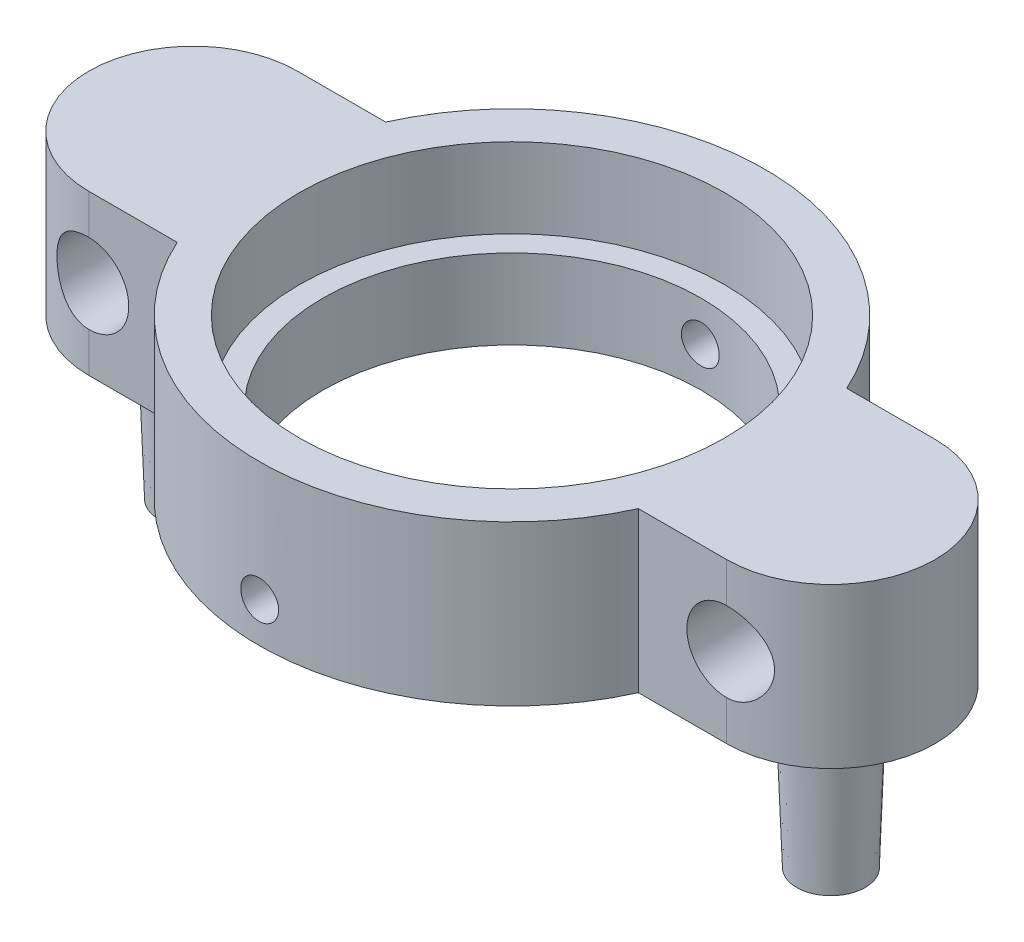
from build123d import *

# Parameters (mm, degrees)
SKETCH1_R                          = 11.303
BOSS_EXTRUDE1_DEPTH                = 9.525
F_4_40_TAPPED_HOLE1_D              = 2.2606
SKETCH10_R                         = 2.38125
BOSS_EXTRUDE2_DEPTH                = 9.525
BOSS_EXTRUDE2_TAPER                = 2
F_3_16_0_1875_DIAMETER_HOLE1_D     = 4.7625
F_3_16_0_1875_DIAMETER_HOLE1_DEPTH = 25.4
F_3_16_0_1875_DIAMETER_HOLE1_TIP   = 1.430799349
SKETCH14_R                         = 12.7
CUT_EXTRUDE1_DEPTH                 = 4.7625


with BuildPart() as part:
    # Sketch1 → Boss-Extrude1 (new body)
    with BuildSketch(Plane(origin=(0, 0, 0), x_dir=(1, 0, 0), z_dir=(0, 1, 0))):
        with BuildLine():
            Line((-19.05, 6.223), (-13.772328779, 6.223))
            ThreePointArc((-13.772328779, 6.223), (0, 15.113), (13.772328779, 6.223))
            Line((13.772328779, 6.223), (19.05, 6.223))
            ThreePointArc((19.05, 6.223), (25.273, 0), (19.05, -6.223))
            Line((19.05, -6.223), (13.772328779, -6.223))
            ThreePointArc((13.772328779, -6.223), (0, -15.113), (-13.772328779, -6.223))
            Line((-13.772328779, -6.223), (-19.05, -6.223))
            ThreePointArc((-19.05, -6.223), (-25.273, 0), (-19.05, 6.223))
        make_face()
        Circle(SKETCH1_R, mode=Mode.SUBTRACT)
    extrude(amount=BOSS_EXTRUDE1_DEPTH)

    # #4-40 Tapped Hole1 (through all)
    with Locations(Plane.XY.offset(15.113)):
        with Locations((0, 2.38125)):
            Hole(F_4_40_TAPPED_HOLE1_D / 2)

    # Sketch10 → Boss-Extrude2 (add)
    with BuildSketch(Plane.XZ):
        with Locations((-19.05, 0)):
            Circle(SKETCH10_R)
        with Locations((19.05, 0)):
            Circle(SKETCH10_R)
    extrude(amount=BOSS_EXTRUDE2_DEPTH, taper=BOSS_EXTRUDE2_TAPER)

    # 3/16 (0.1875) Diameter Hole1
    with Locations(Plane.XY.offset(6.223)):
        with Locations((-19.05, 4.7625), (19.05, 4.7625)):
            Hole(F_3_16_0_1875_DIAMETER_HOLE1_D / 2, depth=F_3_16_0_1875_DIAMETER_HOLE1_DEPTH)
            with Locations((0, 0, -(F_3_16_0_1875_DIAMETER_HOLE1_DEPTH + F_3_16_0_1875_DIAMETER_HOLE1_TIP / 2))):  # 118° drill point
                Cone(0, F_3_16_0_1875_DIAMETER_HOLE1_D / 2, F_3_16_0_1875_DIAMETER_HOLE1_TIP, mode=Mode.SUBTRACT)

    # Sketch14 → Cut-Extrude1 (cut)
    with BuildSketch(Plane(origin=(0, 9.525, 0), x_dir=(1, 0, 0), z_dir=(0, 1, 0))):
        Circle(SKETCH14_R)
    extrude(amount=-CUT_EXTRUDE1_DEPTH, mode=Mode.SUBTRACT)


solid = part.part
